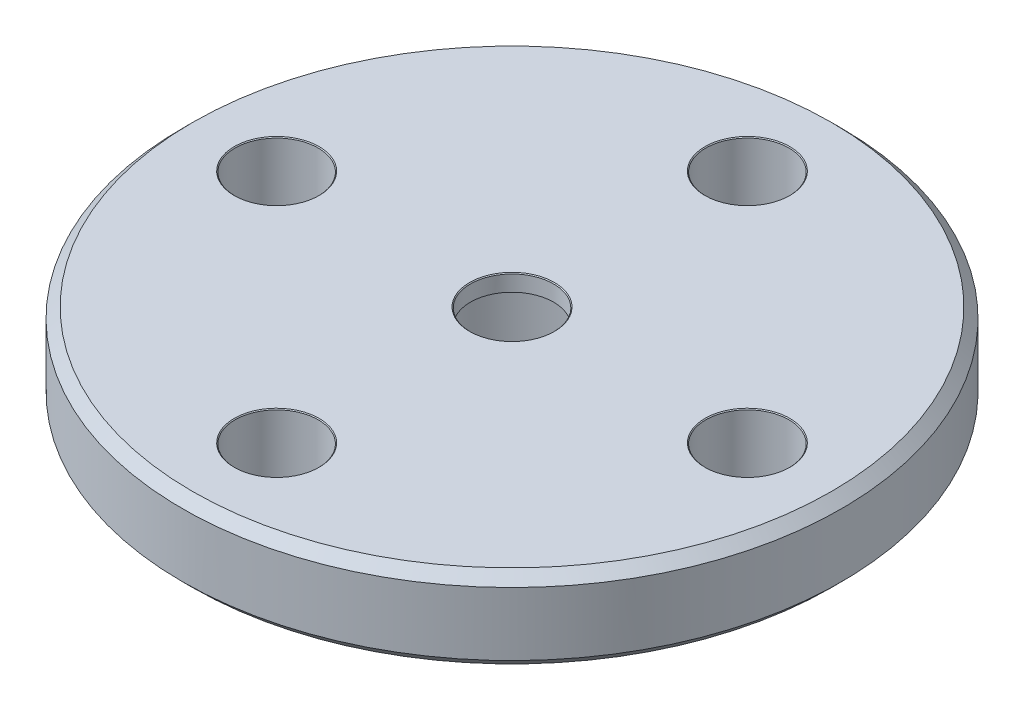
from build123d import *

# Parameters (mm, degrees)
CHAMFER_1_SIZE               = 0.3
HOLE_WIZARD_M3_1_D           = 2.5
HOLE_WIZARD_M3_1_CSINK_D     = 2.55
HOLE_WIZARD_M3_1_CSINK_ANGLE = 90
SKETCH_5_R                   = 2.75
CUT_EXTRUDE_1_DEPTH          = 1
CUT_EXTRUDE_1_DEPTH_BACK     = 4.1


with BuildPart() as part:
    # 草图2 → 旋转1 (revolve)
    with BuildSketch(Plane.XY):
        Polygon((4.95, 0), (0, 0), (0, 4.6), (9.9, 4.6), (9.9, 2.1), (4.95, 2.1), align=None)
    revolve(axis=Axis((0, 0, 0), (0, 1, 0)))

    # 倒角1
    chamfer_1_edges = [part.edges().sort_by_distance(p)[0] for p in [
        (-9.9, 4.6, 0),
        (-9.9, 2.1, 0),
        (-4.95, 0, 0),
    ]]
    chamfer(chamfer_1_edges, length=CHAMFER_1_SIZE)

    # M3 螺纹孔的螺纹孔钻头1 (through all)
    with Locations(Plane(origin=(0, 4.6, 0), x_dir=(1, 0, 0), z_dir=(0, 1, 0))):
        with Locations((7.071067812, 0), (0, -7.071067812), (-7.071067812, 0), (0, 7.071067812), (0, 0)):
            CounterSinkHole(HOLE_WIZARD_M3_1_D / 2, HOLE_WIZARD_M3_1_CSINK_D / 2, counter_sink_angle=HOLE_WIZARD_M3_1_CSINK_ANGLE)

    # 草图5 → 切除-拉伸1 (cut, two sides)
    with BuildSketch(Plane(origin=(0, 0, 0), x_dir=(-1, 0, 0), z_dir=(0, -1, 0))) as cut_extrude_1_sk:
        Circle(SKETCH_5_R)
    extrude(amount=CUT_EXTRUDE_1_DEPTH, mode=Mode.SUBTRACT)
    extrude(cut_extrude_1_sk.sketch, amount=-CUT_EXTRUDE_1_DEPTH_BACK, mode=Mode.SUBTRACT)


solid = part.part
